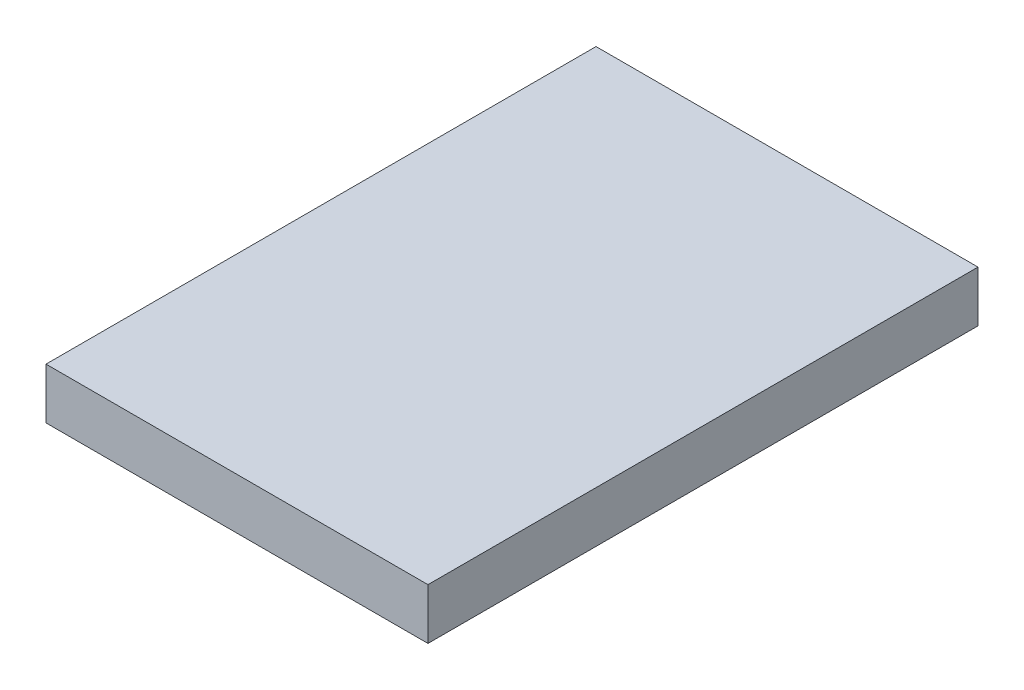
from build123d import *

# Parameters (mm, degrees)
SKETCH1_W           = 7.5
SKETCH1_H           = 10.8
BOSS_EXTRUDE1_DEPTH = 1


with BuildPart() as part:
    # Sketch1 → Boss-Extrude1 (new body)
    with BuildSketch(Plane(origin=(0, 0, 0), x_dir=(1, 0, 0), z_dir=(0, 1, 0))):
        Rectangle(SKETCH1_W, SKETCH1_H)
    extrude(amount=BOSS_EXTRUDE1_DEPTH)


solid = part.part
